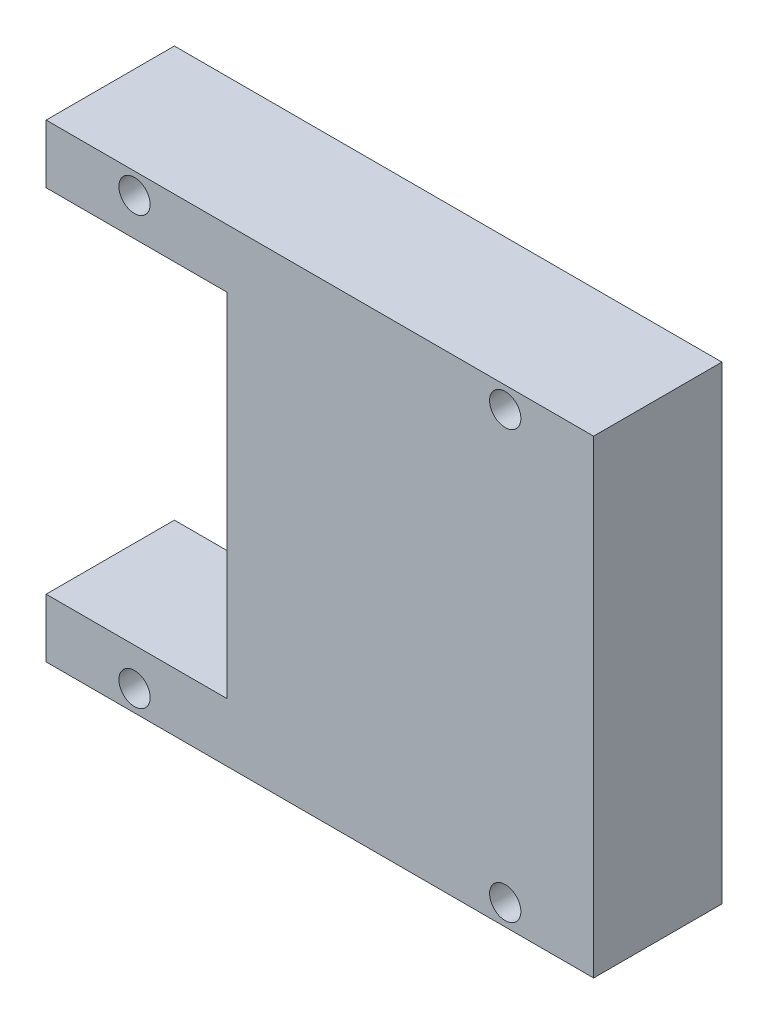
from build123d import *

# Parameters (mm, degrees)
SKETCH3_R           = 1
BOSS_EXTRUDE1_DEPTH = 8.2


with BuildPart() as part:
    # Sketch3 → Boss-Extrude1 (new body)
    with BuildSketch(Plane.XY):
        Polygon((-121.55, -15), (-156.55, -15), (-156.55, -11.25), (-145, -11.25), (-145, 11.25), (-156.55, 11.25), (-156.55, 15), (-121.55, 15), align=None)
        with Locations((-150.9, 13.65)):
            Circle(SKETCH3_R, mode=Mode.SUBTRACT)
        with Locations((-150.9, -13.65)):
            Circle(SKETCH3_R, mode=Mode.SUBTRACT)
        with Locations((-127.2, 13.65)):
            Circle(SKETCH3_R, mode=Mode.SUBTRACT)
        with Locations((-127.2, -13.65)):
            Circle(SKETCH3_R, mode=Mode.SUBTRACT)
    extrude(amount=BOSS_EXTRUDE1_DEPTH)


solid = part.part
